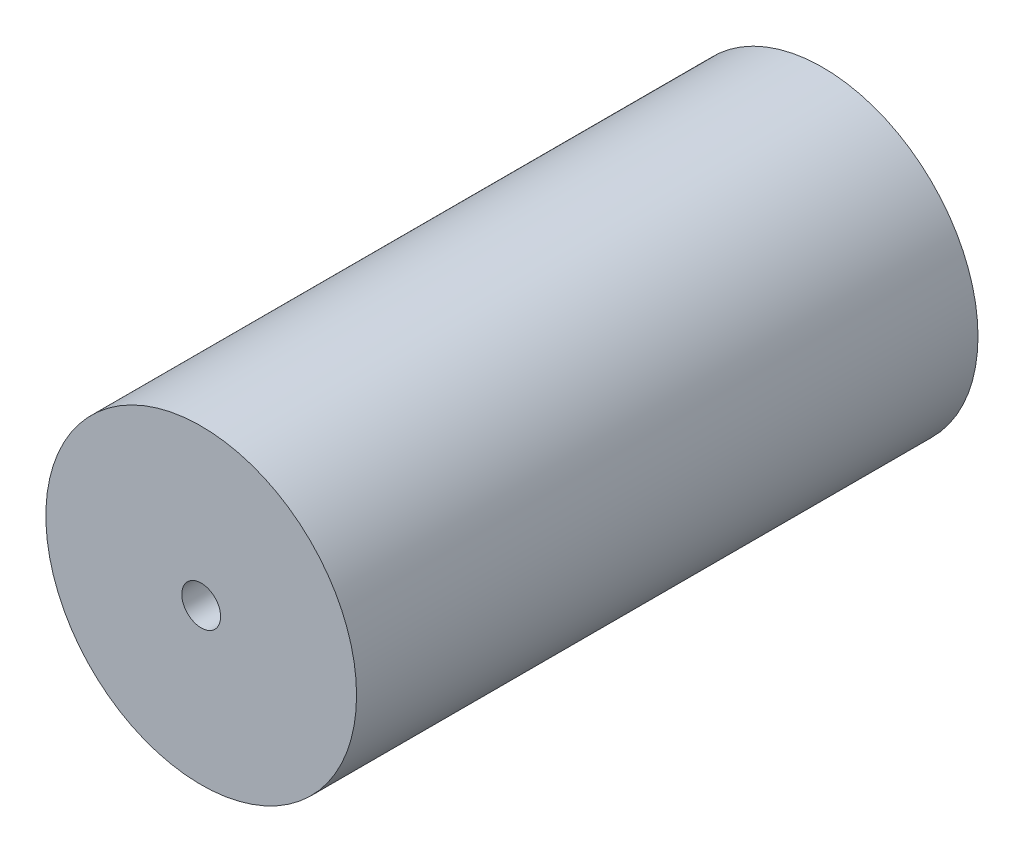
from build123d import *

# Parameters (mm, degrees)
SKETCH_1_R      = 20
SKETCH_1_R_2    = 2.5
EXTRUDE_1_DEPTH = 80


with BuildPart() as part:
    # 草图1 → 凸台-拉伸1 (new body)
    with BuildSketch(Plane.XY):
        Circle(SKETCH_1_R)
        Circle(SKETCH_1_R_2, mode=Mode.SUBTRACT)
    extrude(amount=EXTRUDE_1_DEPTH)


solid = part.part
